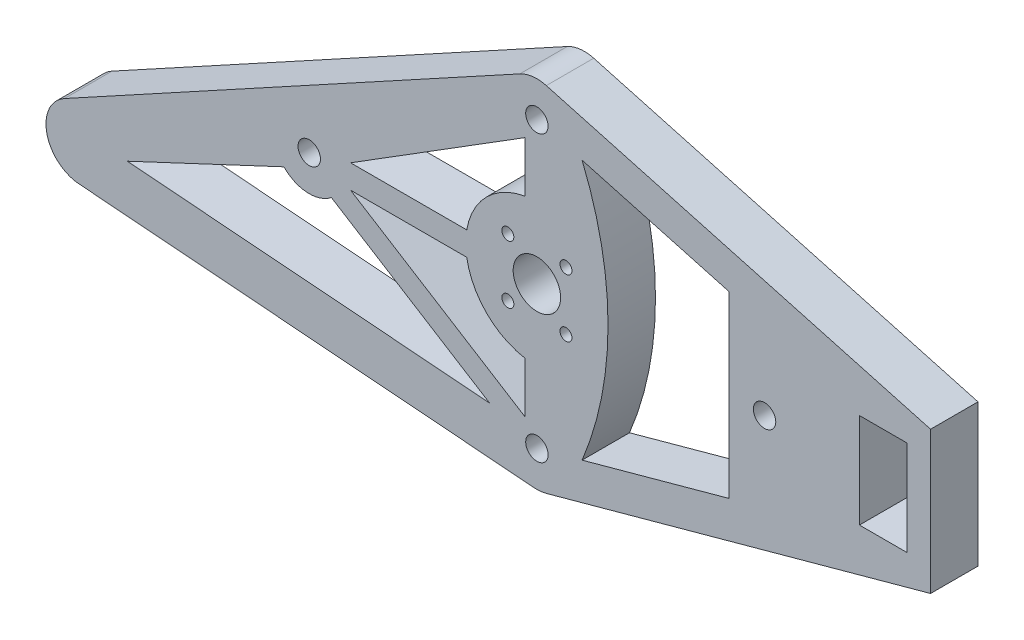
from build123d import *

# Parameters (mm, degrees)
SKETCH1_R           = 3.175
SKETCH1_R_2         = 0.8
SKETCH1_R_3         = 1.5
SKETCH1_W           = 6.35
SKETCH1_H           = 12.7
BOSS_EXTRUDE1_DEPTH = 3.175
CUT_EXTRUDE1_DEPTH  = 7.35
CUT_EXTRUDE2_DEPTH  = 7.35


with BuildPart() as part:
    # Sketch1 → Boss-Extrude1 (new body, symmetric)
    with BuildSketch(Plane.XY):
        with BuildLine():
            Line((52.705, 9.525), (52.705, -9.525))
            Line((52.705, -9.525), (1.260352874, -23.642702569))
            ThreePointArc((1.260352874, -23.642702569), (0.451437295, -23.791055855), (-0.370940015, -23.798032198))
            Line((-0.370940015, -23.798032198), (-61.330940015, -19.035532198))
            ThreePointArc((-61.330940015, -19.035532198), (-65.616640497, -15.286051717), (-63.245106279, -10.109019948))
            Line((-63.245106279, -10.109019948), (-2.285106279, 23.228480052))
            ThreePointArc((-2.285106279, 23.228480052), (-0.552652656, 23.780325707), (1.260352874, 23.642702569))
            Line((1.260352874, 23.642702569), (52.705, 9.525))
        make_face()
        Circle(SKETCH1_R, mode=Mode.SUBTRACT)
        with Locations((-3.889087297, 3.889087297)):
            Circle(SKETCH1_R_2, mode=Mode.SUBTRACT)
        with Locations((3.889087297, -3.889087297)):
            Circle(SKETCH1_R_2, mode=Mode.SUBTRACT)
        with Locations((30.48, 0)):
            Circle(SKETCH1_R_3, mode=Mode.SUBTRACT)
        with Locations((-30.48, 0)):
            Circle(SKETCH1_R_3, mode=Mode.SUBTRACT)
        with Locations((3.889087297, 3.889087297)):
            Circle(SKETCH1_R_2, mode=Mode.SUBTRACT)
        with Locations((-3.889087297, -3.889087297)):
            Circle(SKETCH1_R_2, mode=Mode.SUBTRACT)
        with Locations((0, -19.05)):
            Circle(SKETCH1_R_3, mode=Mode.SUBTRACT)
        with Locations((0, 19.05)):
            Circle(SKETCH1_R_3, mode=Mode.SUBTRACT)
        with Locations((46.355, 0)):
            Rectangle(SKETCH1_W, SKETCH1_H, mode=Mode.SUBTRACT)
    extrude(amount=BOSS_EXTRUDE1_DEPTH, both=True)

    # Sketch2 → Cut-Extrude1 (cut, through all)
    with BuildSketch(Plane.XY.offset(3.175)):
        with BuildLine():
            Line((-6.334889923, -16.962749429), (-54.842346338, -13.173104397))
            Line((-54.842346338, -13.173104397), (-33.871837797, -3.343178518))
            ThreePointArc((-33.871837797, -3.343178518), (-30.766203139, -4.753892512), (-27.513752337, -3.72596042))
            Line((-27.513752337, -3.72596042), (-6.334889923, -16.962749429))
        make_face()
        with BuildLine():
            Line((25.7175, 11.992472423), (25.7175, -11.992472423))
            Line((25.7175, -11.992472423), (6.049537699, -17.389854996))
            ThreePointArc((6.049537699, -17.389854996), (9.525, 0), (6.049537699, 17.389854996))
            Line((6.049537699, 17.389854996), (25.7175, 11.992472423))
        make_face()
    extrude(amount=-CUT_EXTRUDE1_DEPTH, mode=Mode.SUBTRACT)

    # Sketch3 → Cut-Extrude2 (cut, through all)
    with BuildSketch(Plane.XY.offset(3.175)):
        with BuildLine():
            Line((-1.5875, -16.185756869), (-24.944710991, -1.5875))
            Line((-24.944710991, -1.5875), (-9.391776656, -1.5875))
            ThreePointArc((-9.391776656, -1.5875), (-6.735192091, -6.735192091), (-1.5875, -9.391776656))
            Line((-1.5875, -9.391776656), (-1.5875, -16.185756869))
        make_face()
    cut_extrude2 = extrude(amount=-CUT_EXTRUDE2_DEPTH, mode=Mode.SUBTRACT)

    # Mirror1: Cut-Extrude2 across plane
    add(cut_extrude2.mirror(Plane.ZX), mode=Mode.SUBTRACT)


solid = part.part
